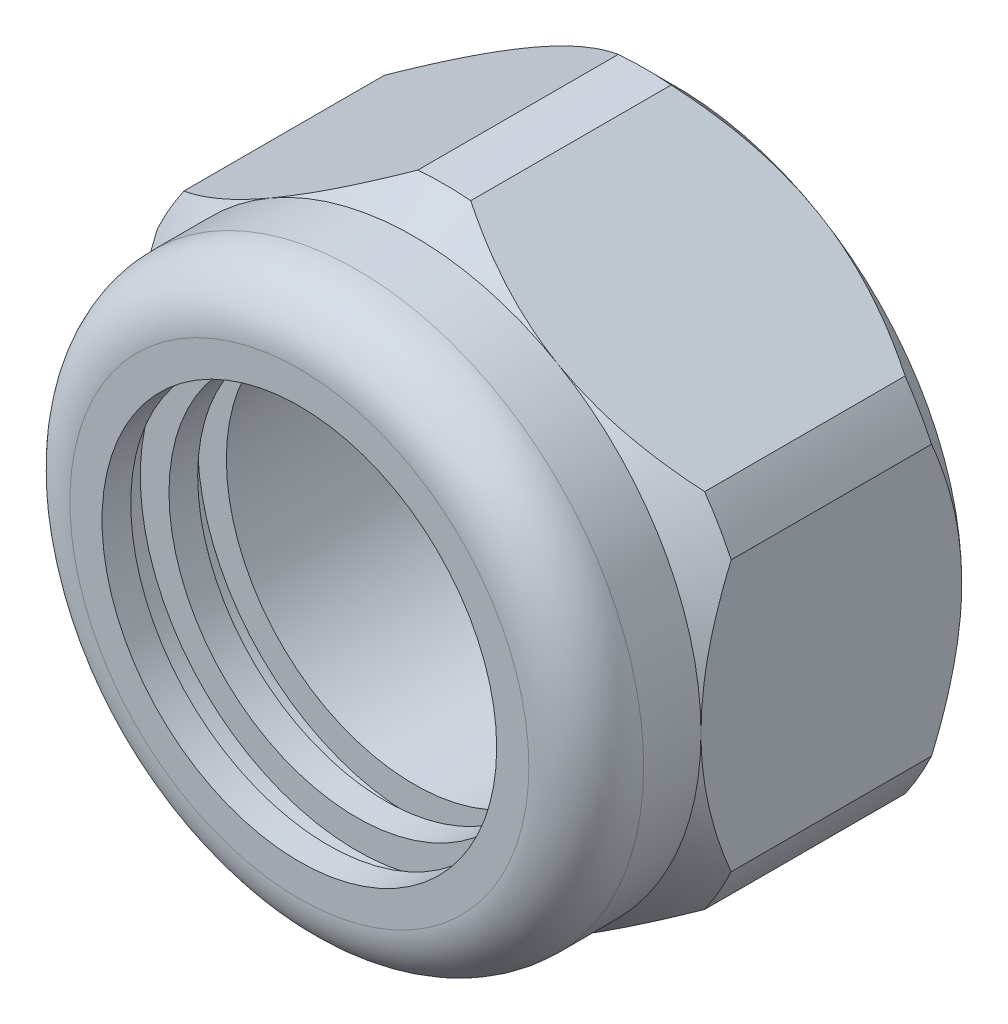
from build123d import *

# Parameters (mm, degrees)
EXTRUDE_2_DEPTH = 36


with BuildPart() as part:
    # Sketch 2 → Revolve 1 (revolve)
    with BuildSketch(Plane(origin=(0, 0, 0), x_dir=(1, 0, 0), z_dir=(0, 1, 0))):
        with BuildLine():
            Line((-18, 25), (-18, 0))
            Line((-18, 0), (-20.75, 0))
            Line((-20.75, 0), (-20.75, -2.75))
            Line((-20.75, -2.75), (-18, -2.75))
            Line((-18, -2.75), (-18, -5.5))
            Line((-18, -5.5), (-20.75, -5.5))
            Line((-20.75, -5.5), (-20.75, -8.25))
            Line((-20.75, -8.25), (-18.916666667, -8.25))
            Line((-18.916666667, -8.25), (-18.916666667, -11))
            Line((-18.916666667, -11), (-22, -11))
            ThreePointArc((-22, -11), (-25.889087297, -9.389087297), (-27.5, -5.5))
            Line((-27.5, -5.5), (-27.5, 0))
            Line((-27.5, 0), (-30.395, 2.895))
            Line((-30.395, 2.895), (-30.395, 22.105))
            Line((-30.395, 22.105), (-27.5, 25))
            Line((-27.5, 25), (-18, 25))
        make_face()
    revolve(axis=Axis((0, 0, 84.230364838), (0, 0, -1)))


with BuildPart() as body_2:
    # Sketch 3 → Extrude 2 (new body)
    with BuildSketch(Plane(origin=(0, 0, -25), x_dir=(-1, 0, 0), z_dir=(0, 0, -1))):
        Polygon((0, -31.754264805), (27.5, -15.877132403), (27.5, 15.877132403), (0, 31.754264805), (-27.5, 15.877132403), (-27.5, -15.877132403), align=None)
    extrude(amount=-EXTRUDE_2_DEPTH)


with BuildPart() as part_1:
    add(part.part)

    # Combine 1: intersect body 2
    add(body_2.part, mode=Mode.INTERSECT)


solid = part_1.part
